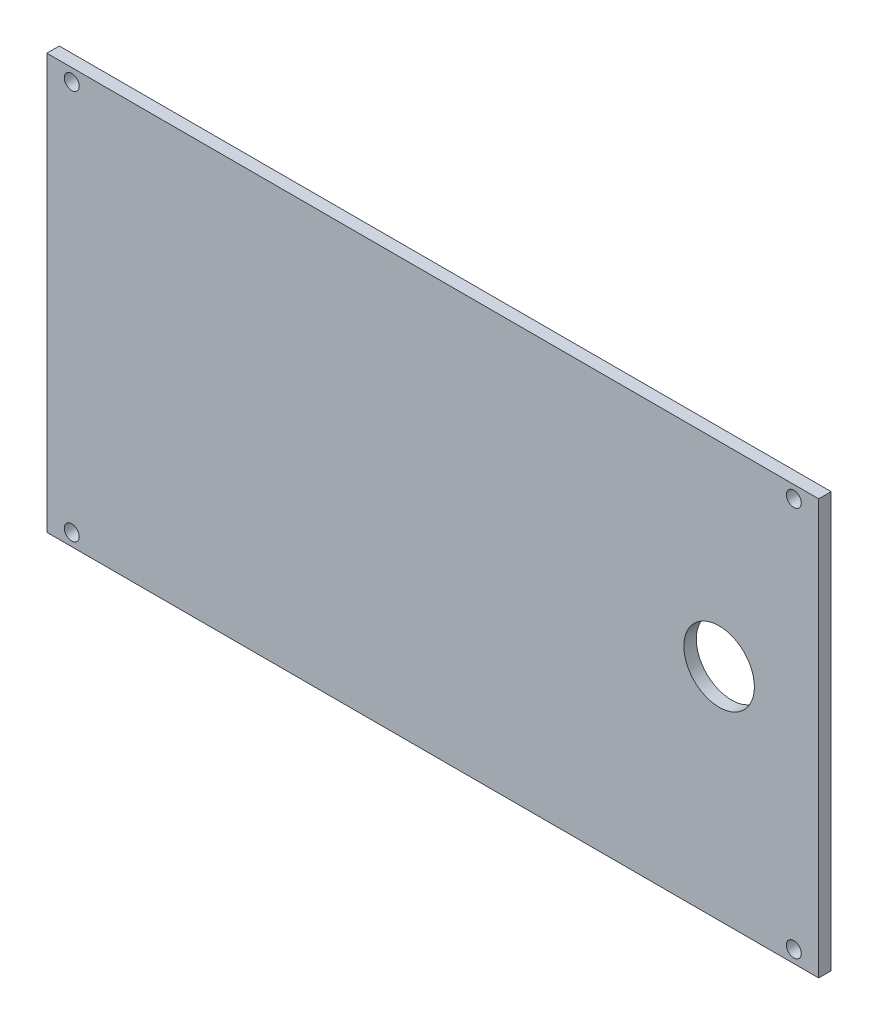
from build123d import *

# Parameters (mm, degrees)
SKETCH1_W           = 186
SKETCH1_H           = 100
BOSS_EXTRUDE1_DEPTH = 3
SKETCH2_R           = 8.5
SKETCH2_R_2         = 1.8
CUT_EXTRUDE1_DEPTH  = 4


with BuildPart() as part:
    # Sketch1 → Boss-Extrude1 (new body)
    with BuildSketch(Plane.XY):
        with Locations((93, 50)):
            Rectangle(SKETCH1_W, SKETCH1_H)
    extrude(amount=BOSS_EXTRUDE1_DEPTH)

    # Sketch2 → Cut-Extrude1 (cut, through all)
    with BuildSketch(Plane.XY.offset(3)):
        with Locations((162, 53)):
            Circle(SKETCH2_R)
        with Locations((180, 3)):
            Circle(SKETCH2_R_2)
        with Locations((180, 97)):
            Circle(SKETCH2_R_2)
        with Locations((6, 3)):
            Circle(SKETCH2_R_2)
        with Locations((6, 97)):
            Circle(SKETCH2_R_2)
    extrude(amount=-CUT_EXTRUDE1_DEPTH, mode=Mode.SUBTRACT)


solid = part.part
